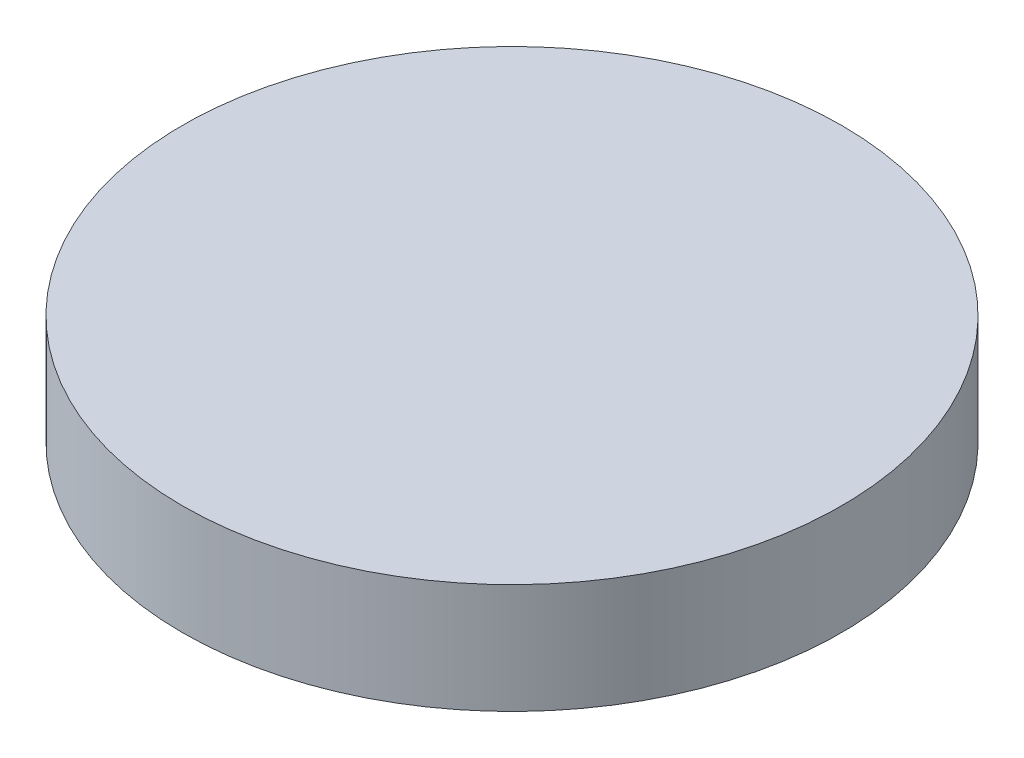
from build123d import *

# Parameters (mm, degrees)
SKETCH_1_R      = 76.2
EXTRUDE_1_DEPTH = 25.4


with BuildPart() as part:
    # 草图1 → 凸台-拉伸1 (new body)
    with BuildSketch(Plane(origin=(0, 0, 0), x_dir=(1, 0, 0), z_dir=(0, 1, 0))):
        with Locations(Location((0, 0, 0), (0, 0, 270))):  # turned: the seam where the file's is
            Circle(SKETCH_1_R)
    extrude(amount=EXTRUDE_1_DEPTH)


solid = part.part
